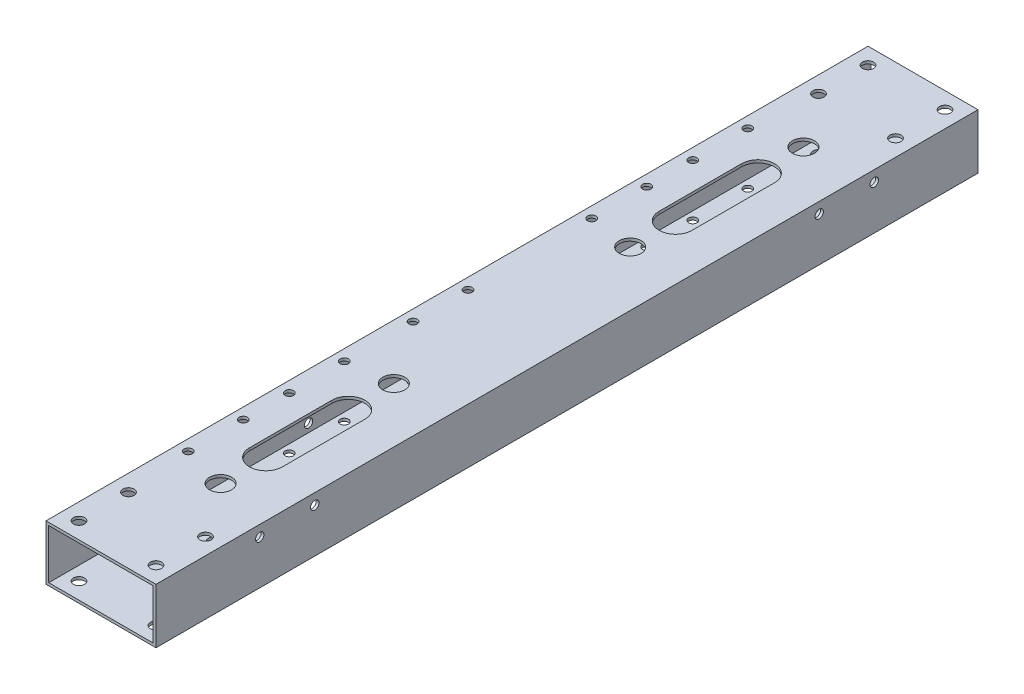
from build123d import *

# Parameters (mm, degrees)
SKETCH_1_W                = 40
SKETCH_1_H                = 20
EXTRUDE_1_DEPTH           = 149.5
SKETCH_2_W                = 38
SKETCH_2_H                = 18
CUT_EXTRUDE_1_DEPTH       = 149.5
SKETCH_4_R                = 1.525
CUT_EXTRUDE_2_DEPTH       = 10
SKETCH_5_R                = 1.525
CUT_EXTRUDE_3_DEPTH       = 21
SKETCH_6_R                = 1.525
CUT_EXTRUDE_4_DEPTH       = 21
SKETCH_7_R                = 1.525
CUT_EXTRUDE_5_DEPTH       = 1
CUT_EXTRUDE_5_DEPTH_BACK  = 41
CUT_EXTRUDE_START         = -21
SKETCH_9_R                = 2.025
CUT_EXTRUDE_6_DEPTH       = 22
CUT_EXTRUDE_7_DEPTH       = 1
CUT_EXTRUDE_7_DEPTH_BACK  = 21
SKETCH_11_R               = 4
CUT_EXTRUDE_8_DEPTH       = 22
SKETCH_12_R               = 1.525
CUT_EXTRUDE_9_DEPTH       = 1
CUT_EXTRUDE_9_DEPTH_BACK  = 21
SKETCH_13_R               = 1.525
CUT_EXTRUDE_10_DEPTH      = 1
CUT_EXTRUDE_10_DEPTH_BACK = 41


with BuildPart() as part:
    # 草图1 → 凸台-拉伸1 (new body, symmetric)
    with BuildSketch(Plane.XY):
        Rectangle(SKETCH_1_W, SKETCH_1_H)
    extrude(amount=EXTRUDE_1_DEPTH, both=True)

    # 草图2 → 切除-拉伸1 (cut, symmetric)
    with BuildSketch(Plane.XY):
        Rectangle(SKETCH_2_W, SKETCH_2_H)
    extrude(amount=CUT_EXTRUDE_1_DEPTH, both=True, mode=Mode.SUBTRACT)

    # 草图4 → 切除-拉伸2 (cut)
    with BuildSketch(Plane.ZY.offset(20)):
        with Locations((55, -6)):
            Circle(SKETCH_4_R)
        with Locations((55, 6)):
            Circle(SKETCH_4_R)
        with Locations((35, 6)):
            Circle(SKETCH_4_R)
        with Locations((35, -6)):
            Circle(SKETCH_4_R)
        with Locations((10, -6)):
            Circle(SKETCH_4_R)
        with Locations((10, 6)):
            Circle(SKETCH_4_R)
        with Locations((-10, 6)):
            Circle(SKETCH_4_R)
        with Locations((-10, -6)):
            Circle(SKETCH_4_R)
        with Locations((-35, 6)):
            Circle(SKETCH_4_R)
        with Locations((-55, -6)):
            Circle(SKETCH_4_R)
        with Locations((-55, 6)):
            Circle(SKETCH_4_R)
        with Locations((-35, -6)):
            Circle(SKETCH_4_R)
    extrude(amount=-CUT_EXTRUDE_2_DEPTH, mode=Mode.SUBTRACT)

    # 草图5 → 切除-拉伸3 (cut, through all)
    with BuildSketch(Plane.XZ.offset(10)):
        with Locations((-16, 65)):
            Circle(SKETCH_5_R)
        with Locations((-16, 45)):
            Circle(SKETCH_5_R)
        with Locations((-16, 20)):
            Circle(SKETCH_5_R)
        with Locations((-16, 0)):
            Circle(SKETCH_5_R)
        with Locations((-16, -45)):
            Circle(SKETCH_5_R)
        with Locations((-16, -65)):
            Circle(SKETCH_5_R)
    extrude(amount=-CUT_EXTRUDE_3_DEPTH, mode=Mode.SUBTRACT)

    # 草图6 → 切除-拉伸4 (cut, through all)
    with BuildSketch(Plane(origin=(0, 10, 0), x_dir=(1, 0, 0), z_dir=(0, 1, 0))):
        with Locations((-16, -81.75)):
            Circle(SKETCH_6_R)
        with Locations((-16, -101.75)):
            Circle(SKETCH_6_R)
    extrude(amount=-CUT_EXTRUDE_4_DEPTH, mode=Mode.SUBTRACT)

    # 草图7 → 切除-拉伸5 (cut, two sides)
    with BuildSketch(Plane.ZY.offset(20)) as cut_extrude_5_sk:
        with Locations((91.75, 6)):
            Circle(SKETCH_7_R)
        with Locations((111.75, 6)):
            Circle(SKETCH_7_R)
    extrude(amount=CUT_EXTRUDE_5_DEPTH, mode=Mode.SUBTRACT)
    extrude(cut_extrude_5_sk.sketch, amount=-CUT_EXTRUDE_5_DEPTH_BACK, mode=Mode.SUBTRACT)

    # 草图9 → 切除-拉伸6 (cut)
    with BuildSketch(Plane.XZ.offset(10).offset(CUT_EXTRUDE_START)):
        with Locations((14, -125.5)):
            Circle(SKETCH_9_R)
        with Locations((-14, -125.5)):
            Circle(SKETCH_9_R)
        with Locations((14, -143.5)):
            Circle(SKETCH_9_R)
        with Locations((-14, -143.5)):
            Circle(SKETCH_9_R)
    cut_extrude_6 = extrude(amount=CUT_EXTRUDE_6_DEPTH, mode=Mode.SUBTRACT)

    # 草图10 → 切除-拉伸7 (cut, two sides)
    with BuildSketch(Plane(origin=(0, 10, 0), x_dir=(1, 0, 0), z_dir=(0, 1, 0))) as cut_extrude_7_sk:
        with BuildLine():
            Line((-6, -89.5), (-6, -59.5))
            ThreePointArc((-6, -59.5), (0, -53.5), (6, -59.5))
            Line((6, -59.5), (6, -89.5))
            ThreePointArc((6, -89.5), (0, -95.5), (-6, -89.5))
        make_face()
        with BuildLine():
            Line((-6, 89.5), (-6, 59.5))
            ThreePointArc((-6, 59.5), (0, 53.5), (6, 59.5))
            Line((6, 59.5), (6, 89.5))
            ThreePointArc((6, 89.5), (0, 95.5), (-6, 89.5))
        make_face()
    extrude(amount=CUT_EXTRUDE_7_DEPTH, mode=Mode.SUBTRACT)
    extrude(cut_extrude_7_sk.sketch, amount=-CUT_EXTRUDE_7_DEPTH_BACK, mode=Mode.SUBTRACT)

    # 草图11 → 切除-拉伸8 (cut)
    with BuildSketch(Plane.XZ.offset(10).offset(CUT_EXTRUDE_START)):
        with Locations((0, -43)):
            Circle(SKETCH_11_R)
        with Locations((0, -106)):
            Circle(SKETCH_11_R)
    cut_extrude_8 = extrude(amount=CUT_EXTRUDE_8_DEPTH, mode=Mode.SUBTRACT)

    # 镜向1: 切除-拉伸8 across plane
    add(cut_extrude_8.mirror(Plane.XY), mode=Mode.SUBTRACT)

    # 镜向2: 切除-拉伸6 across plane
    add(cut_extrude_6.mirror(Plane.XY), mode=Mode.SUBTRACT)

    # 草图12 → 切除-拉伸9 (cut, two sides)
    with BuildSketch(Plane(origin=(0, 10, 0), x_dir=(1, 0, 0), z_dir=(0, 1, 0))) as cut_extrude_9_sk:
        with Locations((-16, 81.75)):
            Circle(SKETCH_12_R)
        with Locations((-16, 101.75)):
            Circle(SKETCH_12_R)
    extrude(amount=CUT_EXTRUDE_9_DEPTH, mode=Mode.SUBTRACT)
    extrude(cut_extrude_9_sk.sketch, amount=-CUT_EXTRUDE_9_DEPTH_BACK, mode=Mode.SUBTRACT)

    # 草图13 → 切除-拉伸10 (cut, two sides)
    with BuildSketch(Plane.ZY.offset(20)) as cut_extrude_10_sk:
        with Locations((-91.75, 6)):
            Circle(SKETCH_13_R)
        with Locations((-111.75, 6)):
            Circle(SKETCH_13_R)
    extrude(amount=CUT_EXTRUDE_10_DEPTH, mode=Mode.SUBTRACT)
    extrude(cut_extrude_10_sk.sketch, amount=-CUT_EXTRUDE_10_DEPTH_BACK, mode=Mode.SUBTRACT)


solid = part.part
